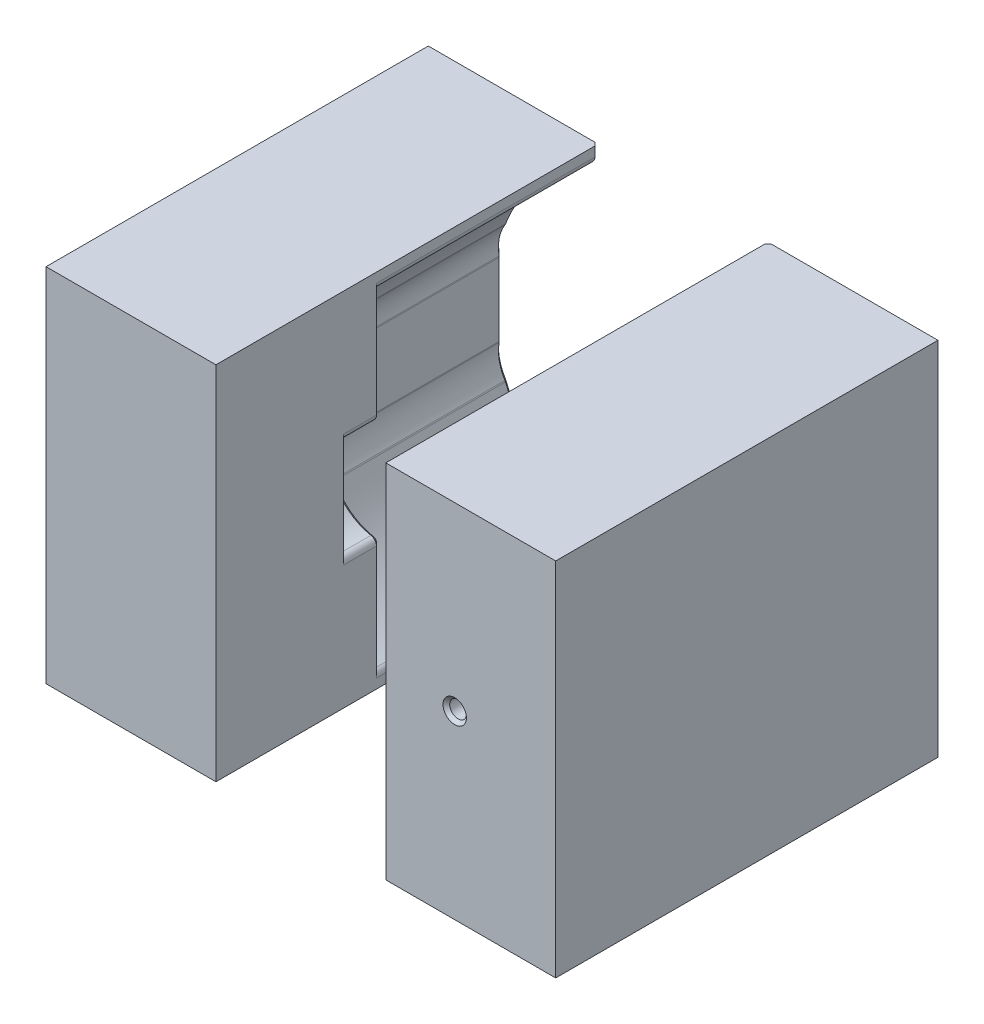
from build123d import *

# Parameters (mm, degrees)
SOFT_JAW_STOCK_SKETCH_W       = 25.4
SOFT_JAW_STOCK_SKETCH_H       = 54
SOFT_JAW_STOCK_DEPTH          = 57.15
SOFT_JAW_STOCK_2_DEPTH        = 57.15
SOFT_JAW_BODY_CUTOUT_DEPTH    = 32.65
SOFT_JAW_CUTOUT_SKETCH_7_R    = 7.62
SOFT_JAW_HOLE_CLEARANCE_DEPTH = 38.1
FILLET1_R                     = 1
FILLET2_R                     = 2
CHAMFER1_SIZE                 = 0.5
CHAMFER2_SIZE                 = 0.5


with BuildPart() as part:
    # soft_jaw_stock_sketch → soft_jaw_stock (new body)
    with BuildSketch(Plane.XY):
        with Locations((25.4, 0)):
            Rectangle(SOFT_JAW_STOCK_SKETCH_W, SOFT_JAW_STOCK_SKETCH_H)
    extrude(amount=SOFT_JAW_STOCK_DEPTH)


with BuildPart() as body_2:
    # soft_jaw_stock_sketch → soft_jaw_stock 2 (new body)
    with BuildSketch(Plane.XY):
        with Locations((-25.4, 0)):
            Rectangle(SOFT_JAW_STOCK_SKETCH_W, SOFT_JAW_STOCK_SKETCH_H)
    extrude(amount=SOFT_JAW_STOCK_2_DEPTH)


with BuildPart() as soft_jaw_body_cutout_tool:
    # soft_jaw_cutout_sketch → soft_jaw_body_cutout (new body)
    with BuildSketch(Plane.XY):
        with BuildLine():
            ThreePointArc((-26.095423855, 10.150312992), (-26.99213364, 7.926098963), (-27, 5.527942461))
            Line((-27, 5.527942461), (-27, -5.527942461))
            ThreePointArc((-27, -5.527942461), (-26.99213364, -7.926098963), (-26.095423855, -10.150312992))
            ThreePointArc((-26.095423855, -10.150312992), (-20.761976894, -18.786705817), (-12.7, -24.95415797))
            Line((-12.7, -24.95415797), (-12.7, 24.95415797))
            ThreePointArc((-12.7, 24.95415797), (-20.761976894, 18.786705817), (-26.095423855, 10.150312992))
        make_face()
        with BuildLine():
            ThreePointArc((26.095423855, -10.150312992), (26.99213364, -7.926098963), (27, -5.527942461))
            Line((27, -5.527942461), (27, 5.527942461))
            ThreePointArc((27, 5.527942461), (26.99213364, 7.926098963), (26.095423855, 10.150312992))
            ThreePointArc((26.095423855, 10.150312992), (20.761976894, 18.786705817), (12.7, 24.95415797))
            Line((12.7, 24.95415797), (12.7, -24.95415797))
            ThreePointArc((12.7, -24.95415797), (20.761976894, -18.786705817), (26.095423855, -10.150312992))
        make_face()
    extrude(amount=SOFT_JAW_BODY_CUTOUT_DEPTH)


with BuildPart() as part_1:
    add(part.part)

    # soft_jaw_body_cutout: cut by soft_jaw_body_cutout_tool
    add(soft_jaw_body_cutout_tool.part, mode=Mode.SUBTRACT)


with BuildPart() as body_2_1:
    add(body_2.part)

    # soft_jaw_body_cutout: cut by soft_jaw_body_cutout_tool
    add(soft_jaw_body_cutout_tool.part, mode=Mode.SUBTRACT)


with BuildPart() as soft_jaw_hole_clearance_tool:
    # soft_jaw_cutout_sketch_7 → soft_jaw_hole_clearance (new body)
    with BuildSketch(Plane.XY):
        with Locations((-12.133259165, 0)):
            Circle(SOFT_JAW_CUTOUT_SKETCH_7_R)
        with Locations((12.133259165, 0)):
            Circle(SOFT_JAW_CUTOUT_SKETCH_7_R)
    extrude(amount=SOFT_JAW_HOLE_CLEARANCE_DEPTH)


with BuildPart() as part_2:
    add(part_1.part)

    # soft_jaw_hole_clearance: cut by soft_jaw_hole_clearance_tool
    add(soft_jaw_hole_clearance_tool.part, mode=Mode.SUBTRACT)

    # Sketch3 → alignment_pin_hole (revolve, cut)
    with BuildSketch(Plane(origin=(23, 0, 32.65), x_dir=(0, 1, 0), z_dir=(1, 0, 0))):
        Polygon((0, 0), (0, 24.5), (1.75, 24.5), (1.25, 24), (1.25, 0.5), (1.75, 0), align=None)
    revolve(axis=Axis((23, 0, 26.3), (0, 0, 1)), mode=Mode.SUBTRACT)

    # Fillet2
    fillet2_edges = [part_2.edges().sort_by_distance(p)[0] for p in [
        (26.095423855, 10.150312992, 16.325),
        (12.7, 24.95415797, 16.325),
        (12.7, -24.95415797, 16.325),
        (26.095423855, -10.150312992, 16.325),
        (27, -5.527942461, 16.325),
        (27, 5.527942461, 16.325),
        (12.7, -7.598894974, 35.375),
        (12.7, 7.598894974, 35.375),
    ]]
    fillet(fillet2_edges, radius=FILLET2_R)

    # Chamfer1
    chamfer1_edges = [part_2.edges().sort_by_distance(p)[0] for p in [
        (12.7, -17.711465941, 32.65),
        (12.7, 26.575836493, 0),
        (19.753259165, 0, 32.65),
        (12.7, 17.711465941, 32.65),
        (13.108263227, -8.06031957, 32.65),
        (13.108263227, 8.06031957, 32.65),
        (12.7, -26.575836493, 0),
        (21.086700189, 18.421484065, 0),
        (21.086700189, -18.421484065, 0),
        (26.993097288, -7.921164374, 0),
        (27, 0, 0),
        (26.993097288, 7.921164374, 0),
        (12.97373235, -25.141722493, 0),
        (26.099203165, -10.162005275, 0),
        (27.006618191, -5.516169884, 0),
        (27.006618191, 5.516169884, 0),
        (26.099203165, 10.162005275, 0),
        (12.97373235, 25.141722493, 0),
    ]]
    chamfer(chamfer1_edges, length=CHAMFER1_SIZE)


with BuildPart() as body_2_2:
    add(body_2_1.part)

    # soft_jaw_hole_clearance: cut by soft_jaw_hole_clearance_tool
    add(soft_jaw_hole_clearance_tool.part, mode=Mode.SUBTRACT)

    # Fillet1
    fillet1_edges = [body_2_2.edges().sort_by_distance(p)[0] for p in [
        (-12.7, 24.95415797, 16.325),
        (-26.095423855, 10.150312992, 16.325),
        (-27, 5.527942461, 16.325),
        (-27, -5.527942461, 16.325),
        (-12.7, -24.95415797, 16.325),
        (-26.095423855, -10.150312992, 16.325),
        (-12.7, -7.598894974, 35.375),
        (-12.7, 7.598894974, 35.375),
    ]]
    fillet(fillet1_edges, radius=FILLET1_R)

    # Chamfer2
    chamfer2_edges = [body_2_2.edges().sort_by_distance(p)[0] for p in [
        (-12.7, -17.018175589, 32.65),
        (-12.7, 26.279964789, 0),
        (-19.753259165, 0, 32.65),
        (-12.7, 17.018175589, 32.65),
        (-12.7, -26.279964789, 0),
        (-12.931313953, -7.836795334, 32.65),
        (-12.931313953, 7.836795334, 32.65),
        (-20.928900221, -18.60056815, 0),
        (-20.928900221, 18.60056815, 0),
        (-26.992732561, 7.923034492, 0),
        (-27, 0, 0),
        (-26.992732561, -7.923034492, 0),
        (-12.841975002, 25.04632165, 0),
        (-26.098439519, 10.154727337, 0),
        (-27.003760162, 5.52441143, 0),
        (-27.003760162, -5.52441143, 0),
        (-26.098439519, -10.154727337, 0),
        (-12.841975002, -25.04632165, 0),
    ]]
    chamfer(chamfer2_edges, length=CHAMFER2_SIZE)


solid = Compound([part_2.part, body_2_2.part])
